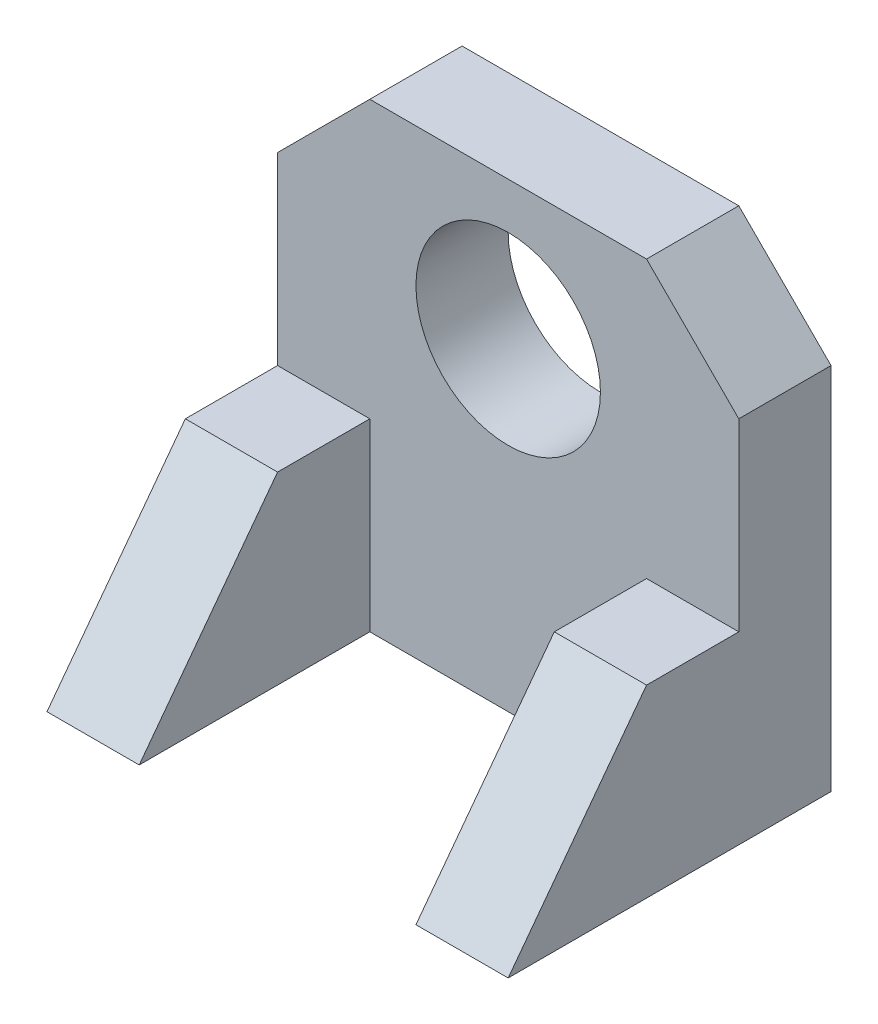
from build123d import *

# Parameters (mm, degrees)
BOSS_EXTRUDE1_DEPTH = 10
SKETCH2_R           = 10
CUT_EXTRUDE1_DEPTH  = 10
BOSS_EXTRUDE2_DEPTH = 10
BOSS_EXTRUDE3_DEPTH = 10


with BuildPart() as part:
    # Sketch1 → Boss-Extrude1 (new body)
    with BuildSketch(Plane.XY):
        Polygon((-15.751690718, 35.056562454), (14.248309282, 35.056562454), (24.248309282, 25.056562454), (24.248309282, -14.943437546), (-25.751690718, -14.943437546), (-25.751690718, 25.056562454), align=None)
    extrude(amount=-BOSS_EXTRUDE1_DEPTH)

    # Sketch2 → Cut-Extrude1 (cut)
    with BuildSketch(Plane.XY):
        with Locations((-0.751690718, 20.056562454)):
            Circle(SKETCH2_R)
    extrude(amount=-CUT_EXTRUDE1_DEPTH, mode=Mode.SUBTRACT)

    # Sketch3 → Boss-Extrude2 (add)
    with BuildSketch(Plane(origin=(24.248309282, 0, 0), x_dir=(0, 0, -1), z_dir=(1, 0, 0))):
        Polygon((0, -14.943437546), (-25, -14.943437546), (-10, 5.056562454), (0, 5.056562454), align=None)
    extrude(amount=-BOSS_EXTRUDE2_DEPTH)

    # Sketch4 → Boss-Extrude3 (add)
    with BuildSketch(Plane.ZY.offset(25.751690718)):
        Polygon((0, -14.943437546), (25, -14.943437546), (10, 5.056562454), (0, 5.056562454), align=None)
    extrude(amount=-BOSS_EXTRUDE3_DEPTH)


solid = part.part
